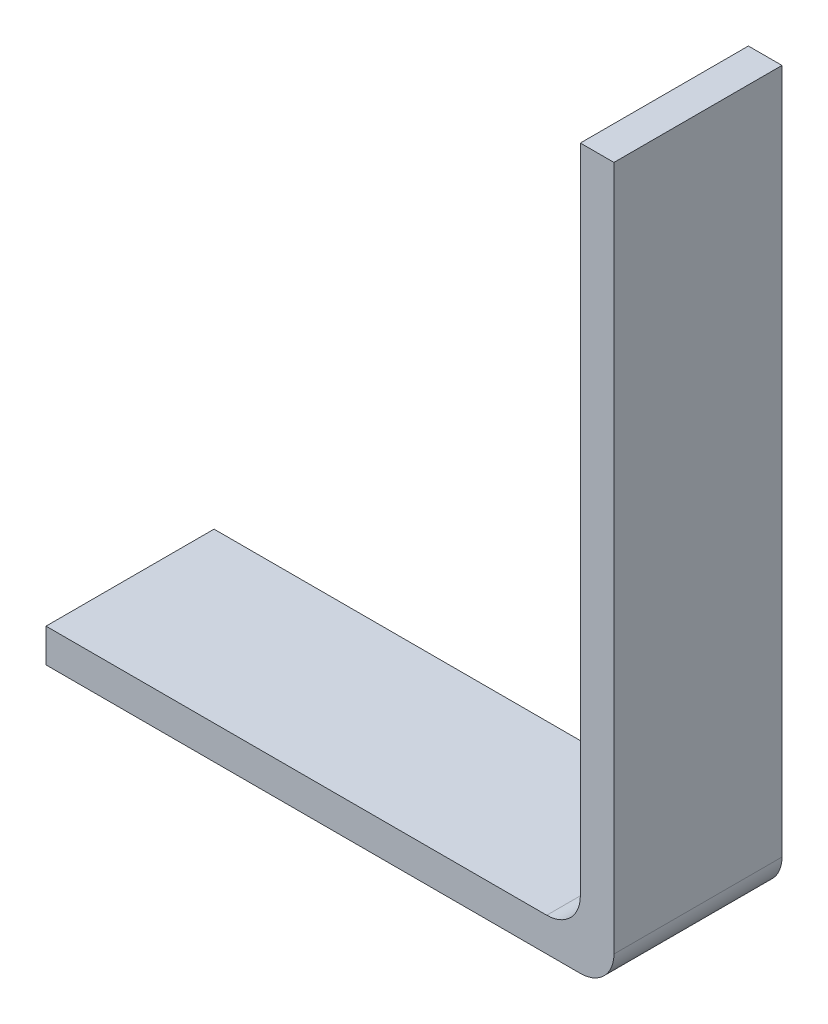
from build123d import *

# Parameters (mm, degrees)
EXTRUDE_THIN1_DEPTH = 5
FILLET1_R           = 1


with BuildPart() as part:
    # Sketch1 → Extrude-Thin1 (new body)
    with BuildSketch(Plane.XY):
        Polygon((0, 0), (15.9, 0), (15.9, 20.4), (16.9, 20.4), (16.9, -1), (0, -1), align=None)
    extrude(amount=EXTRUDE_THIN1_DEPTH)

    # Fillet1
    fillet1_edges = [part.edges().sort_by_distance(p)[0] for p in [
        (16.9, -1, 2.5),
        (15.9, 0, 2.5),
    ]]
    fillet(fillet1_edges, radius=FILLET1_R)


solid = part.part
